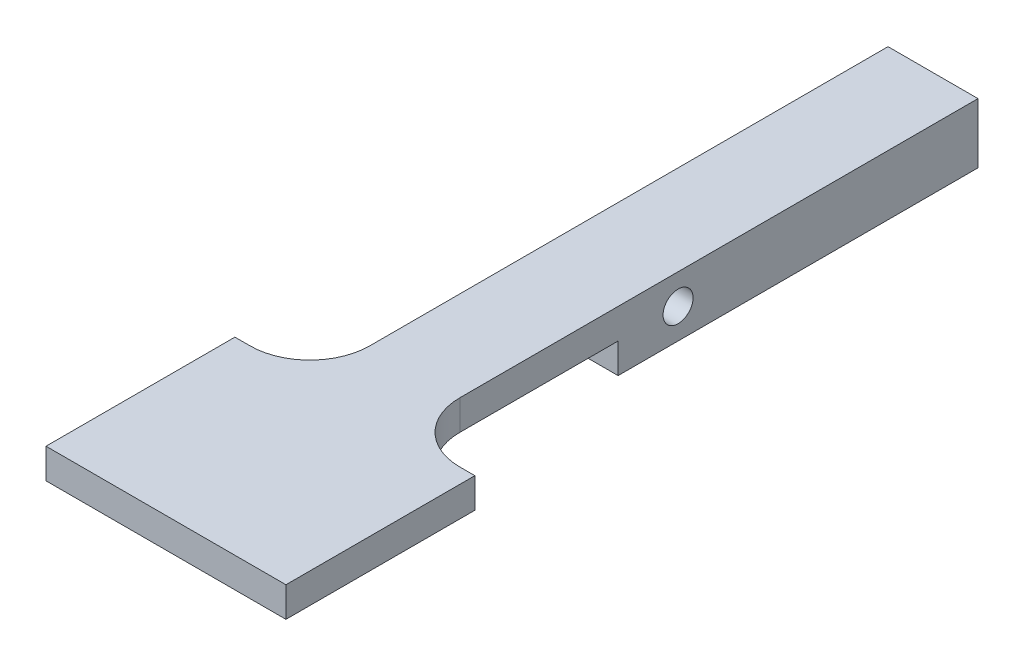
from build123d import *

# Parameters (mm, degrees)
SKETCH1_R           = 1.5875
BOSS_EXTRUDE1_DEPTH = 9.525
SKETCH3_W           = 15
SKETCH3_H           = 3.175
SKETCH3_W_2         = 5
BOSS_EXTRUDE2_DEPTH = 12.7
FILLET1_R           = 6.35


with BuildPart() as part:
    # Sketch1 → Boss-Extrude1 (new body)
    with BuildSketch(Plane(origin=(0, 0, 0), x_dir=(0, 0, -1), z_dir=(1, 0, 0))):
        Polygon((0, -1.5875), (0, 1.5875), (-76.2, 1.5875), (-76.2, -1.5875), (-38.1, -1.5875), (-38.1, -4.7625), (-25.4, -4.7625), (0, -4.7625), align=None)
        with Locations((-31.75, -1.5875)):
            Circle(SKETCH1_R, mode=Mode.SUBTRACT)
        Polygon((0, -1.5875), (0, 1.5875), (-76.2, 1.5875), (-76.2, -1.5875), (-38.1, -1.5875), (-38.1, -4.7625), (-25.4, -4.7625), (0, -4.7625), align=None)
        with Locations((-31.75, -1.5875)):
            Circle(SKETCH1_R, mode=Mode.SUBTRACT)
    extrude(amount=BOSS_EXTRUDE1_DEPTH)

    # Sketch3 → Boss-Extrude2 (add, symmetric)
    with BuildSketch(Plane(origin=(4.7625, 0, 0), x_dir=(0, 0, -1), z_dir=(1, 0, 0))):
        with Locations((-68.7, 0)):
            Rectangle(SKETCH3_W, SKETCH3_H)
        with Locations((-78.7, 0)):
            Rectangle(SKETCH3_W_2, SKETCH3_H)
    extrude(amount=BOSS_EXTRUDE2_DEPTH, both=True)

    # Fillet1
    fillet1_edges = [part.edges().sort_by_distance(p)[0] for p in [
        (0, 0, 61.2),
        (9.525, 0, 61.2),
    ]]
    fillet(fillet1_edges, radius=FILLET1_R)


solid = part.part
